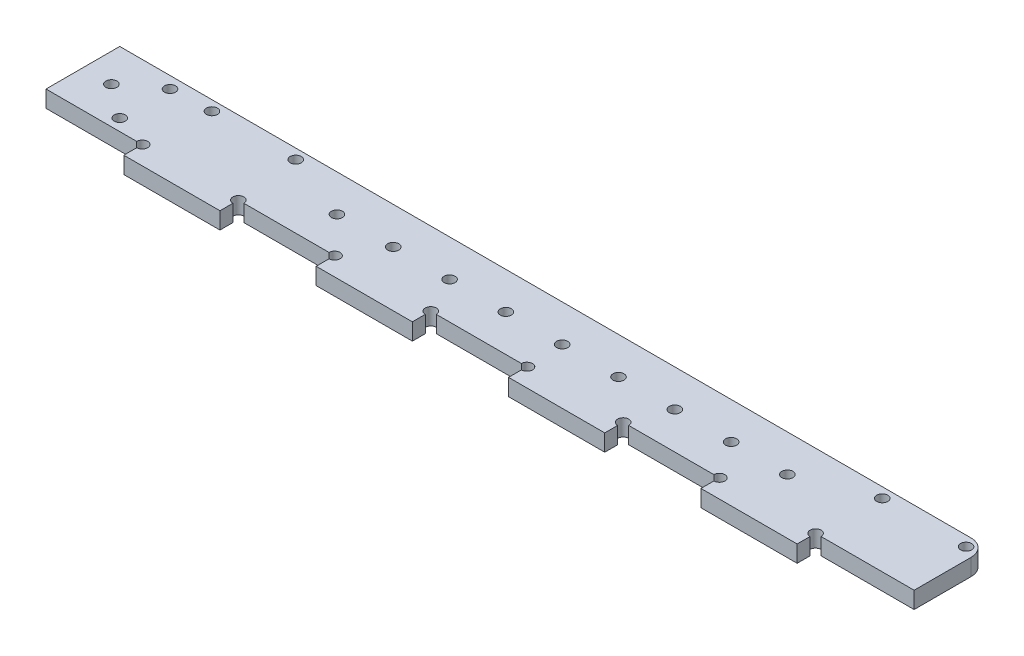
from build123d import *

# Parameters (mm, degrees)
SKETCH1_R           = 1.65
BOSS_EXTRUDE1_DEPTH = 5
SKETCH4_W           = 28.7
SKETCH4_H           = 5.5
BOSS_EXTRUDE3_DEPTH = 5
SKETCH5_R           = 1.65
CUT_EXTRUDE2_DEPTH  = 6
SKETCH6_R           = 1.65
CUT_EXTRUDE3_DEPTH  = 6
FILLET1_R           = 5


with BuildPart() as part:
    # Sketch1 → Boss-Extrude1 (new body)
    with BuildSketch(Plane(origin=(0, 0, 0), x_dir=(1, 0, 0), z_dir=(0, 1, 0))):
        Polygon((0, 0), (227, 0), (259, 0), (259, 22), (227, 22), (0, 22), align=None)
        with Locations((230.5, 19)):
            Circle(SKETCH1_R, mode=Mode.SUBTRACT)
        with Locations((255.5, 19)):
            Circle(SKETCH1_R, mode=Mode.SUBTRACT)
        with Locations((30.5, 19)):
            Circle(SKETCH1_R, mode=Mode.SUBTRACT)
        with Locations((55.5, 19)):
            Circle(SKETCH1_R, mode=Mode.SUBTRACT)
        with Locations((8.5, 11)):
            Circle(SKETCH1_R, mode=Mode.SUBTRACT)
        with Locations((18.5, 18.5)):
            Circle(SKETCH1_R, mode=Mode.SUBTRACT)
        with Locations((18.5, 3.5)):
            Circle(SKETCH1_R, mode=Mode.SUBTRACT)
    extrude(amount=BOSS_EXTRUDE1_DEPTH)

    # Sketch4 → Boss-Extrude3 (add)
    with BuildSketch(Plane(origin=(0, 5, 0), x_dir=(1, 0, 0), z_dir=(0, 1, 0))):
        with Locations((43.05, -2.75)):
            Rectangle(SKETCH4_W, SKETCH4_H)
        with Locations((100.45, -2.75)):
            Rectangle(SKETCH4_W, SKETCH4_H)
        with Locations((157.85, -2.75)):
            Rectangle(SKETCH4_W, SKETCH4_H)
        with Locations((215.25, -2.75)):
            Rectangle(SKETCH4_W, SKETCH4_H)
    extrude(amount=-BOSS_EXTRUDE3_DEPTH)

    # Sketch5 → Cut-Extrude2 (cut, through all)
    with BuildSketch(Plane(origin=(0, 5, 0), x_dir=(1, 0, 0), z_dir=(0, 1, 0))):
        with Locations((28.7, 0)):
            Circle(SKETCH5_R)
        with Locations((57.4, 0)):
            Circle(SKETCH5_R)
        with Locations((86.1, 0)):
            Circle(SKETCH5_R)
        with Locations((114.8, 0)):
            Circle(SKETCH5_R)
        with Locations((143.5, 0)):
            Circle(SKETCH5_R)
        with Locations((172.2, 0)):
            Circle(SKETCH5_R)
        with Locations((200.9, 0)):
            Circle(SKETCH5_R)
        with Locations((229.6, 0)):
            Circle(SKETCH5_R)
    extrude(amount=-CUT_EXTRUDE2_DEPTH, mode=Mode.SUBTRACT)

    # Sketch6 → Cut-Extrude3 (cut, through all)
    with BuildSketch(Plane(origin=(0, 5, 0), x_dir=(1, 0, 0), z_dir=(0, 1, 0))):
        with Locations((75.8, 11)):
            Circle(SKETCH6_R)
        with Locations((92.6, 11)):
            Circle(SKETCH6_R)
        with Locations((109.4, 11)):
            Circle(SKETCH6_R)
        with Locations((126.2, 11)):
            Circle(SKETCH6_R)
        with Locations((143, 11)):
            Circle(SKETCH6_R)
        with Locations((159.8, 11)):
            Circle(SKETCH6_R)
        with Locations((176.6, 11)):
            Circle(SKETCH6_R)
        with Locations((193.4, 11)):
            Circle(SKETCH6_R)
        with Locations((210.2, 11)):
            Circle(SKETCH6_R)
    extrude(amount=-CUT_EXTRUDE3_DEPTH, mode=Mode.SUBTRACT)

    # Fillet1
    fillet1_edges = [part.edges().sort_by_distance(p)[0] for p in [
        (259, 2.5, -22),
    ]]
    fillet(fillet1_edges, radius=FILLET1_R)


solid = part.part
